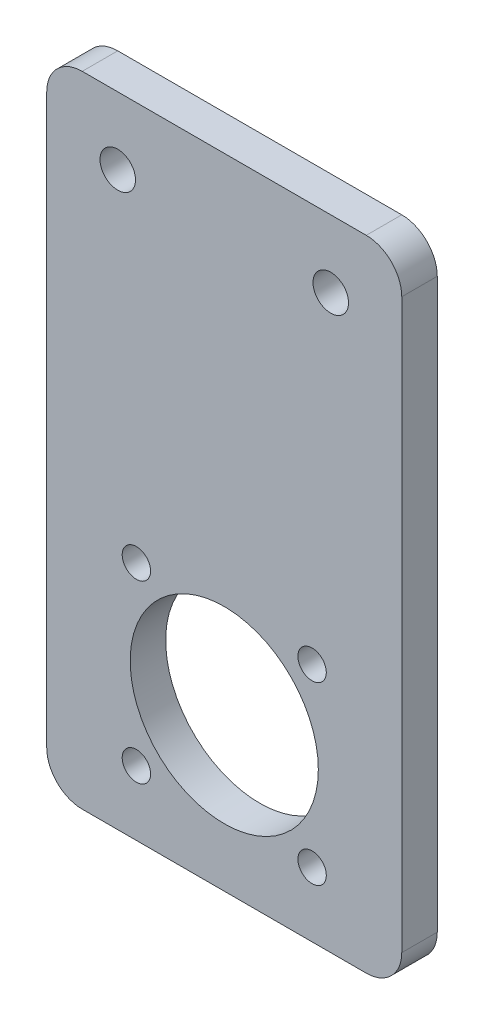
from build123d import *

# Parameters (mm, degrees)
SKETCH1_W           = 50
SKETCH1_H           = 90
SKETCH1_R           = 2.5
SKETCH1_R_2         = 2
SKETCH1_R_3         = 13.25
BOSS_EXTRUDE1_DEPTH = 5
FILLET1_R           = 5


with BuildPart() as part:
    # Sketch1 → Boss-Extrude1 (new body)
    with BuildSketch(Plane.XY):
        with Locations((25, -45)):
            Rectangle(SKETCH1_W, SKETCH1_H)
        with Locations((10, -9.5)):
            Circle(SKETCH1_R, mode=Mode.SUBTRACT)
        with Locations((40, -9.5)):
            Circle(SKETCH1_R, mode=Mode.SUBTRACT)
        with Locations((37.374368671, -56.150631329)):
            Circle(SKETCH1_R_2, mode=Mode.SUBTRACT)
        with Locations((37.374368671, -80.899368671)):
            Circle(SKETCH1_R_2, mode=Mode.SUBTRACT)
        with Locations((12.625631329, -80.899368671)):
            Circle(SKETCH1_R_2, mode=Mode.SUBTRACT)
        with Locations((12.625631329, -56.150631329)):
            Circle(SKETCH1_R_2, mode=Mode.SUBTRACT)
        with Locations((25, -68.525)):
            Circle(SKETCH1_R_3, mode=Mode.SUBTRACT)
    extrude(amount=BOSS_EXTRUDE1_DEPTH)

    # Fillet1
    fillet1_edges = [part.edges().sort_by_distance(p)[0] for p in [
        (0, 0, 2.5),
        (50, 0, 2.5),
        (50, -90, 2.5),
        (0, -90, 2.5),
    ]]
    fillet(fillet1_edges, radius=FILLET1_R)


solid = part.part
